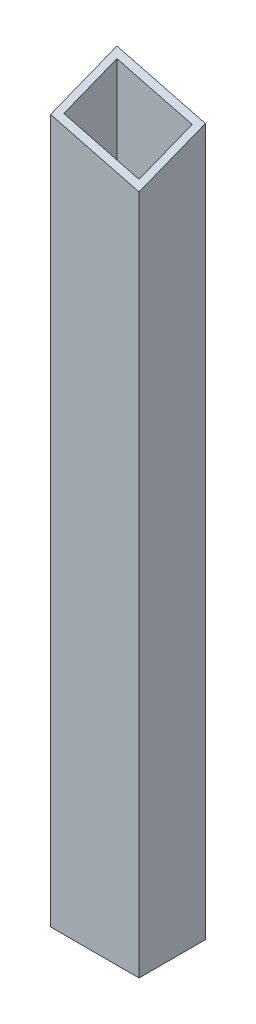
from build123d import *

# Parameters (mm, degrees)
SKETCH1_W           = 40
SKETCH1_H           = 30
SKETCH1_W_2         = 34
SKETCH1_H_2         = 24
EXTRUDE_THIN1_DEPTH = 330
EXTRUDE1_DEPTH      = 41
EXTRUDE2_DEPTH      = 33.318373456


with BuildPart() as part:
    # Sketch1 → Extrude-Thin1 (new body)
    with BuildSketch(Plane(origin=(0, 0, 0), x_dir=(1, 0, 0), z_dir=(0, 1, 0))):
        Rectangle(SKETCH1_W, SKETCH1_H)
        Rectangle(SKETCH1_W_2, SKETCH1_H_2, mode=Mode.SUBTRACT)
    extrude(amount=EXTRUDE_THIN1_DEPTH)

    # Sketch2 → Extrude1 (cut, through all)
    with BuildSketch(Plane.ZY.offset(20)):
        Polygon((-15, 330), (15, 330), (15, 318.182685732), align=None)
    extrude(amount=-EXTRUDE1_DEPTH, mode=Mode.SUBTRACT)

    # Sketch3 → Extrude2 (cut, through all, along a direction that is not the sketch's normal)
    with BuildSketch(Plane(origin=(0, 0, -15), x_dir=(-1, 0, 0), z_dir=(0, 0, -1))):
        Polygon((20, 330), (-20, 330), (-20, 319.655296626), align=None)
    extrude(amount=-EXTRUDE2_DEPTH, dir=(0, 0.366501227, -0.930417568), mode=Mode.SUBTRACT)


solid = part.part
